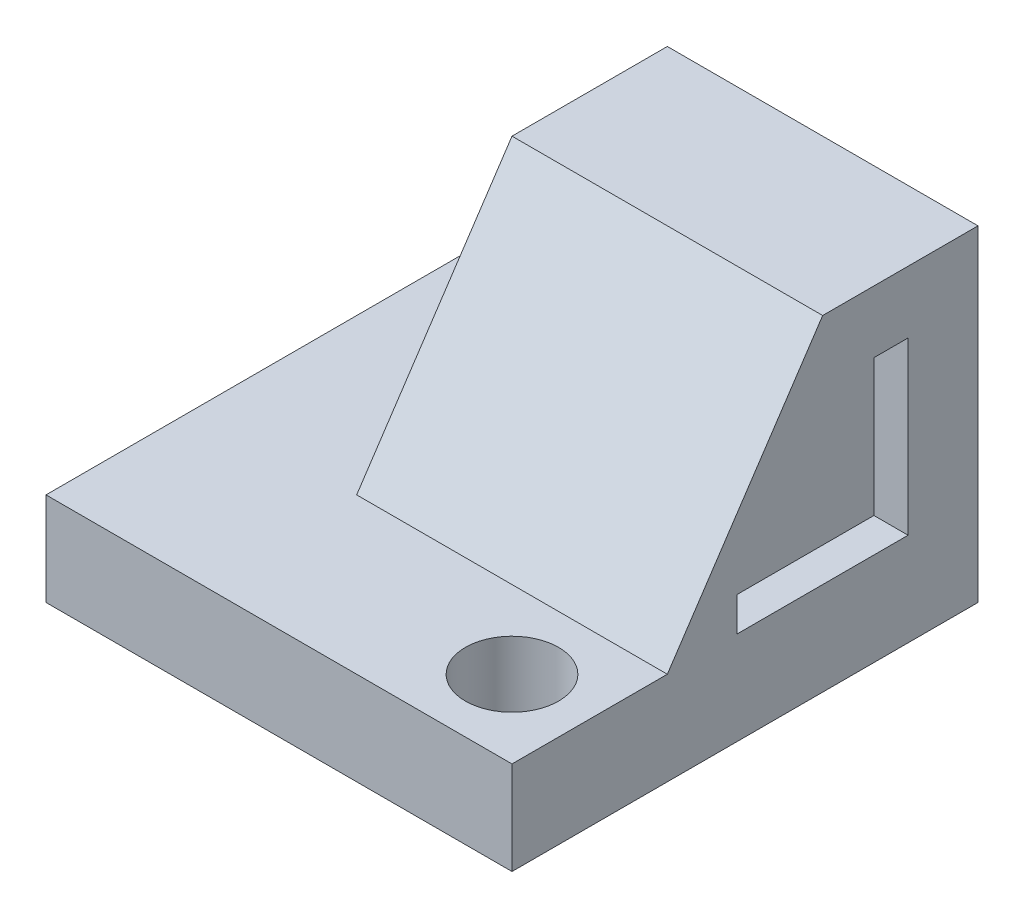
from build123d import *

# Parameters (mm, degrees)
SKETCH1_W           = 38.1
SKETCH1_H           = 38.1
BOSS_EXTRUDE1_DEPTH = 7.62
SKETCH2_W           = 25.4
SKETCH2_H           = 25.4
BOSS_EXTRUDE2_DEPTH = 19.05
CUT_EXTRUDE1_REACH  = 9.62
SKETCH3_R           = 3.81
CUT_EXTRUDE2_DEPTH  = 6.35
CUT_EXTRUDE3_REACH  = 40.1


with BuildPart() as part:
    # Sketch1 → Boss-Extrude1 (new body)
    with BuildSketch(Plane(origin=(0, 0, 0), x_dir=(1, 0, 0), z_dir=(0, 1, 0))):
        Rectangle(SKETCH1_W, SKETCH1_H)
    extrude(amount=BOSS_EXTRUDE1_DEPTH)

    # Sketch2 → Boss-Extrude2 (add)
    with BuildSketch(Plane(origin=(0, 7.62, 0), x_dir=(1, 0, 0), z_dir=(0, 1, 0))):
        with Locations((6.35, 6.35)):
            Rectangle(SKETCH2_W, SKETCH2_H)
    extrude(amount=BOSS_EXTRUDE2_DEPTH)

    # Sketch3 → Cut-Extrude1 (cut, up to next)
    with BuildSketch(Plane(origin=(0, 7.62, 0), x_dir=(1, 0, 0), z_dir=(0, 1, 0)), mode=Mode.PRIVATE) as cut_extrude1_sk1:
        with Locations((-12.7, 12.7)):
            Circle(SKETCH3_R)
    cut_extrude1_tool1 = extrude(cut_extrude1_sk1.sketch, amount=-CUT_EXTRUDE1_REACH, mode=Mode.PRIVATE) & part.part
    add(cut_extrude1_tool1.solids().sort_by_distance((-12.7, 7.62, -12.7))[0], mode=Mode.SUBTRACT)
    # Sketch3 → Cut-Extrude1 (cut, up to next)
    with BuildSketch(Plane(origin=(0, 7.62, 0), x_dir=(1, 0, 0), z_dir=(0, 1, 0)), mode=Mode.PRIVATE) as cut_extrude1_sk2:
        with Locations((12.7, -12.7)):
            Circle(SKETCH3_R)
    cut_extrude1_tool2 = extrude(cut_extrude1_sk2.sketch, amount=-CUT_EXTRUDE1_REACH, mode=Mode.PRIVATE) & part.part
    add(cut_extrude1_tool2.solids().sort_by_distance((12.7, 7.62, 12.7))[0], mode=Mode.SUBTRACT)

    # Sketch4 → Cut-Extrude2 (cut)
    with BuildSketch(Plane(origin=(19.05, 0, 0), x_dir=(0, 0, -1), z_dir=(1, 0, 0))):
        Polygon((10.541, 21.59), (13.335, 21.59), (13.335, 7.62), (-0.635, 7.62), (-0.635, 10.414), (10.541, 10.414), align=None)
    extrude(amount=-CUT_EXTRUDE2_DEPTH, mode=Mode.SUBTRACT)

    # Sketch5 → Cut-Extrude3 (cut, up to next)
    with BuildSketch(Plane(origin=(19.05, 0, 0), x_dir=(0, 0, -1), z_dir=(1, 0, 0)), mode=Mode.PRIVATE) as cut_extrude3_sk1:
        Polygon((6.35, 26.67), (-6.35, 7.62), (-6.35, 26.67), align=None)
    cut_extrude3_tool1 = extrude(cut_extrude3_sk1.sketch, amount=-CUT_EXTRUDE3_REACH, mode=Mode.PRIVATE) & part.part
    add(cut_extrude3_tool1.solids().sort_by_distance((19.05, 20.32, 2.116667))[0], mode=Mode.SUBTRACT)


solid = part.part
